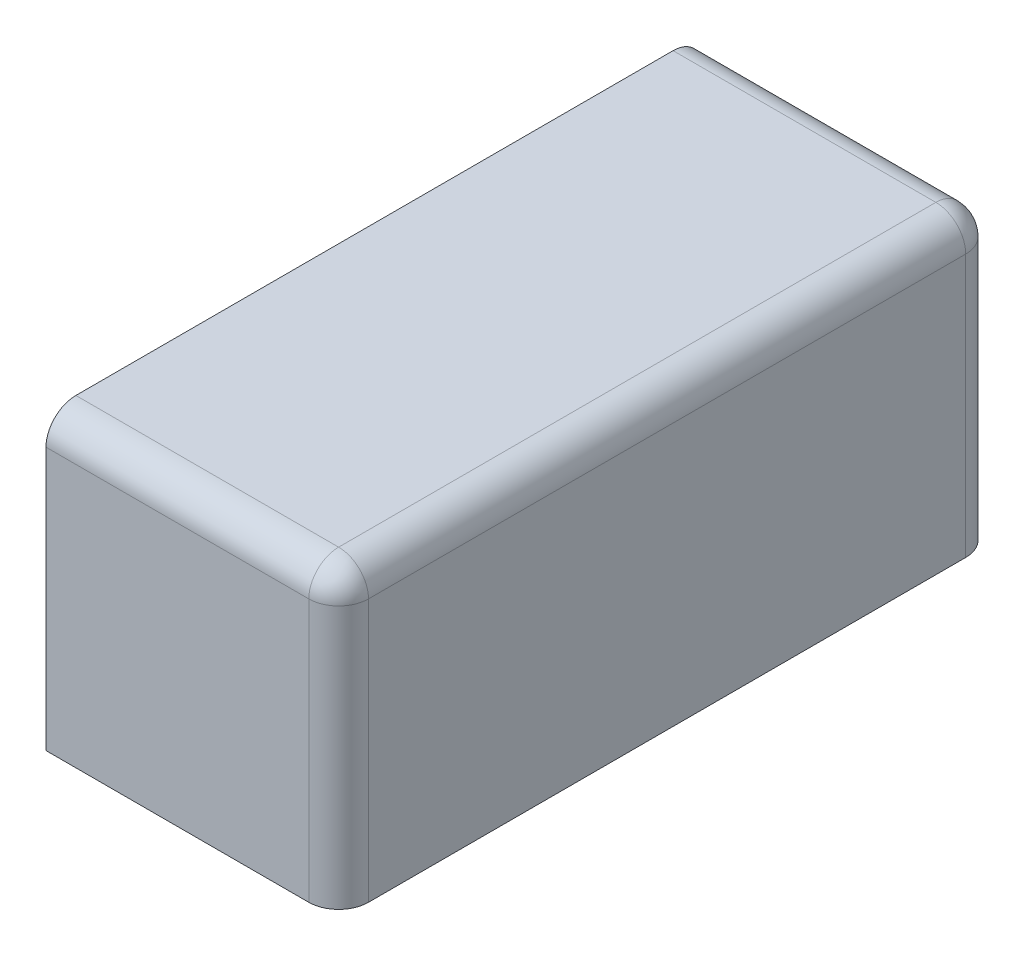
from build123d import *

# Parameters (mm, degrees)
CROQUIS1_W              = 9.8
CROQUIS1_H              = 9.8
SALIENTE_EXTRUIR1_DEPTH = 22
REDONDEO1_R             = 1
CROQUIS2_R              = 1.5
CORTAR_EXTRUIR1_DEPTH   = 7
CROQUIS3_R              = 2
CORTAR_EXTRUIR2_DEPTH   = 5.2


with BuildPart() as part:
    # Croquis1 → Saliente-Extruir1 (new body)
    with BuildSketch(Plane.XY):
        with Locations((-4.9, 4.9)):
            Rectangle(CROQUIS1_W, CROQUIS1_H)
    extrude(amount=SALIENTE_EXTRUIR1_DEPTH)

    # Redondeo1
    redondeo1_edges = [part.edges().sort_by_distance(p)[0] for p in [
        (0, 4.9, 22),
        (-4.9, 9.8, 0),
        (0, 4.9, 0),
        (0, 9.8, 11),
        (-4.9, 9.8, 22),
    ]]
    fillet(redondeo1_edges, radius=REDONDEO1_R)

    # Croquis2 → Cortar-Extruir1 (cut)
    with BuildSketch(Plane.ZY.offset(9.8)):
        with Locations((11, 4.4)):
            Circle(CROQUIS2_R)
    extrude(amount=-CORTAR_EXTRUIR1_DEPTH, mode=Mode.SUBTRACT)

    # Croquis3 → Cortar-Extruir2 (cut)
    with BuildSketch(Plane.XZ):
        with Locations((-5.4, 18.5)):
            Circle(CROQUIS3_R)
        with Locations((-5.4, 3.5)):
            Circle(CROQUIS3_R)
    extrude(amount=-CORTAR_EXTRUIR2_DEPTH, mode=Mode.SUBTRACT)


solid = part.part
